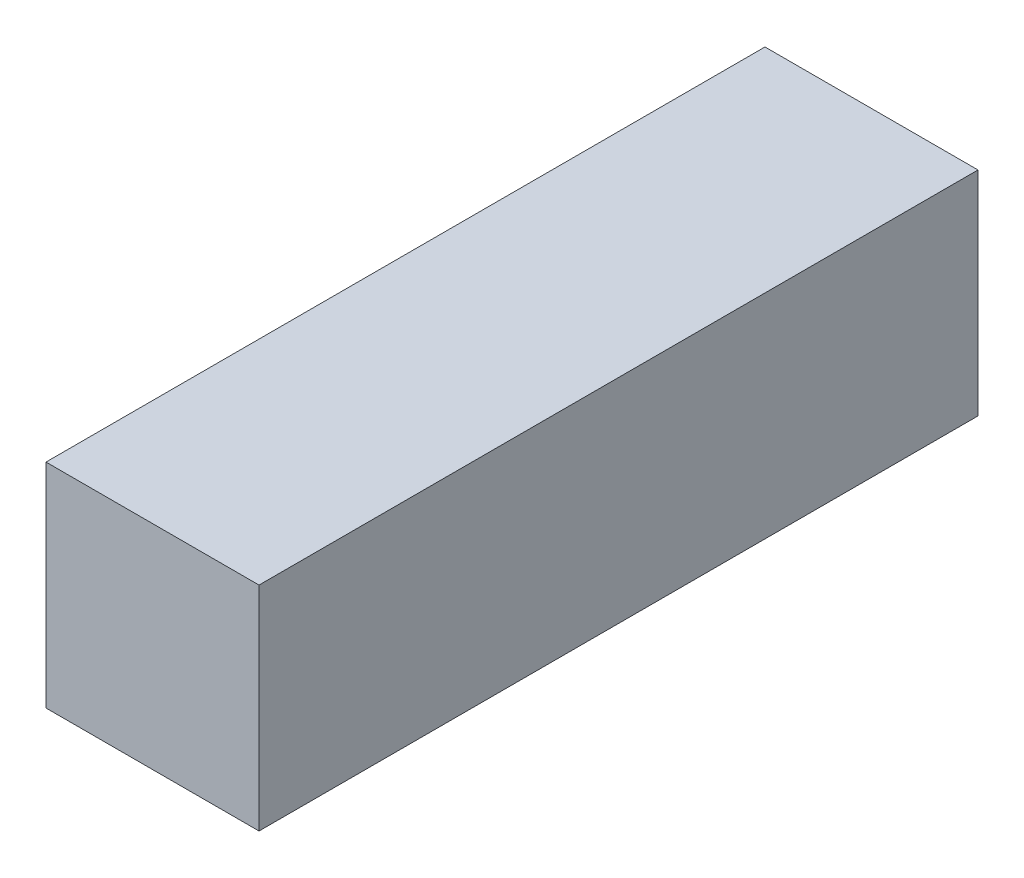
from build123d import *

# Parameters (mm, degrees)
SKETCH_1_W      = 8
SKETCH_1_H      = 8
EXTRUDE_1_DEPTH = 27


with BuildPart() as part:
    # Эскиз1 → Бобышка-Вытянуть1 (new body)
    with BuildSketch(Plane.XY):
        with Locations((-12, 0)):
            Rectangle(SKETCH_1_W, SKETCH_1_H)
    extrude(amount=EXTRUDE_1_DEPTH)


solid = part.part
